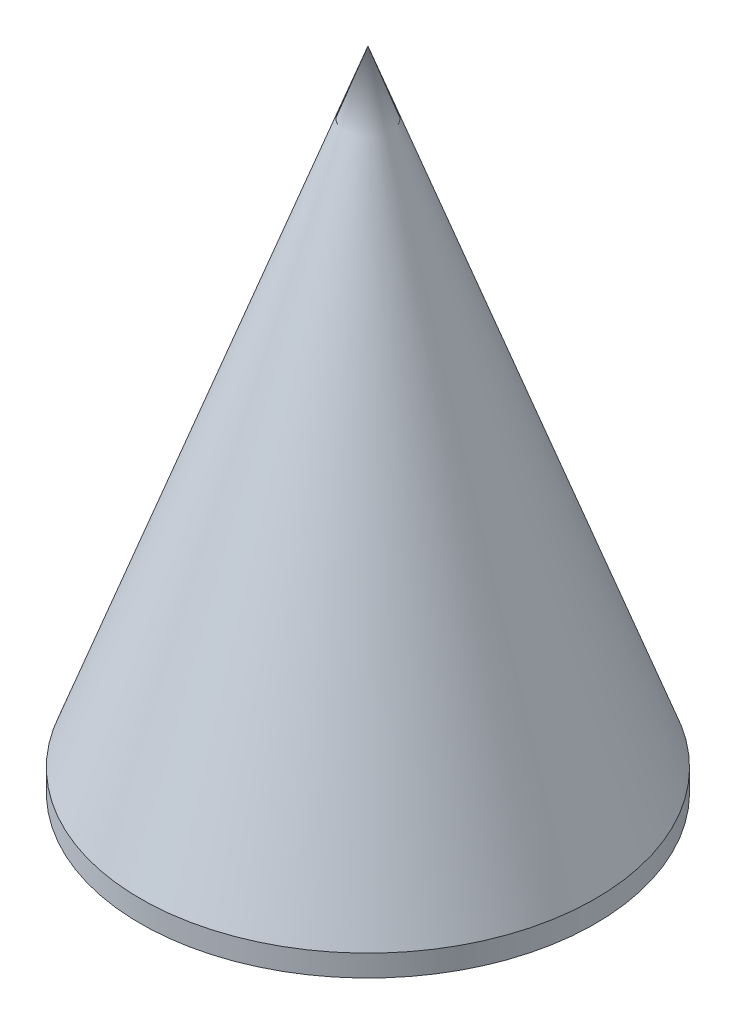
from build123d import *


with BuildPart() as part:
    # Sketch1 → Revolve1 (revolve)
    with BuildSketch(Plane.XY):
        Polygon((-1.5875, 0), (-22.225, 0), (-22.225, 2.1082), (0, 63.170885647), (0, 60.309662663), (-21.1836, 2.1082), (-6.35, 2.1082), (-6.35, 6.35), (-1.5875, 6.35), (-1.5875, 2.1082), align=None)
    revolve(axis=Axis((0, 0, 0), (0, 1, 0)))


solid = part.part
